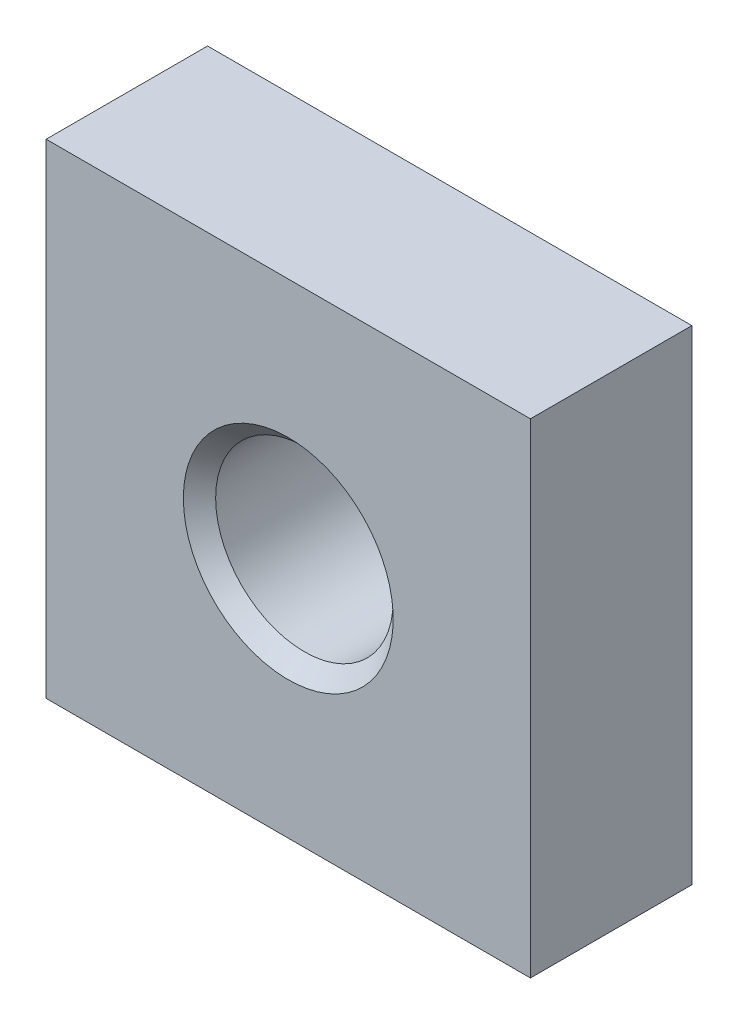
from build123d import *

# Parameters (mm, degrees)
SKETCH_1_W      = 60
SKETCH_1_H      = 60
SKETCH_1_R      = 11
EXTRUDE_1_DEPTH = 20
CHAMFER_1_SIZE  = 2


with BuildPart() as part:
    # Эскиз1 → Бобышка-Вытянуть1 (new body)
    with BuildSketch(Plane.XY):
        with Locations((30, 30)):
            Rectangle(SKETCH_1_W, SKETCH_1_H)
        with Locations((30, 30)):
            Circle(SKETCH_1_R, mode=Mode.SUBTRACT)
    extrude(amount=-EXTRUDE_1_DEPTH)

    # Фаска1
    chamfer_1_edges = [part.edges().sort_by_distance(p)[0] for p in [
        (19, 30, -20),
        (19, 30, 0),
    ]]
    chamfer(chamfer_1_edges, length=CHAMFER_1_SIZE)


solid = part.part
